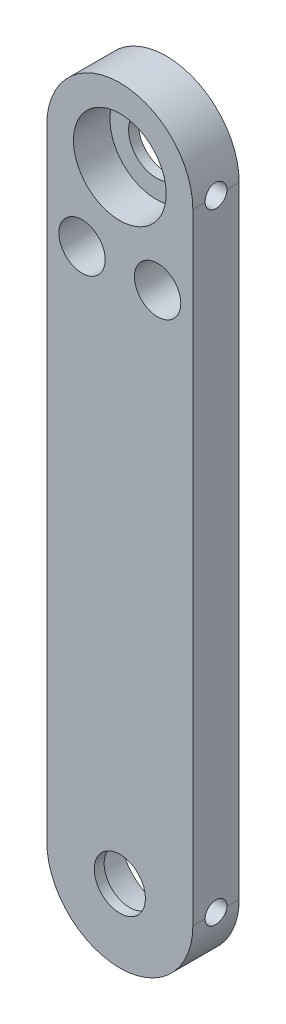
from build123d import *

# Parameters (mm, degrees)
SALIENTE_EXTRUIR1_DEPTH = 6.35
CROQUIS2_R              = 6.35
CORTAR_EXTRUIR1_DEPTH   = 5
CROQUIS3_R              = 3.8
CORTAR_EXTRUIR2_DEPTH   = 54.677276384
CROQUIS4_R              = 3.175
CORTAR_EXTRUIR3_DEPTH   = 5
CROQUIS5_R              = 1.5
CORTAR_EXTRUIR4_DEPTH   = 5
CROQUIS6_R              = 1.5
CORTAR_EXTRUIR5_DEPTH   = 5
CROQUIS7_R              = 6.35
CORTAR_EXTRUIR6_DEPTH   = 5
CROQUIS8_R              = 3.5
CORTAR_EXTRUIR7_DEPTH   = 5
CROQUIS9_R              = 1.5
CORTAR_EXTRUIR8_DEPTH   = 5


with BuildPart() as part:
    # Croquis1 → Saliente-Extruir1 (new body)
    with BuildSketch(Plane.XY):
        with BuildLine():
            Line((10, 42.5), (10, -42.5))
            ThreePointArc((10, -42.5), (0, -52.5), (-10, -42.5))
            Line((-10, -42.5), (-10, 42.5))
            ThreePointArc((-10, 42.5), (0, 52.5), (10, 42.5))
        make_face()
    extrude(amount=SALIENTE_EXTRUIR1_DEPTH)

    # Croquis2 → Cortar-Extruir1 (cut)
    with BuildSketch(Plane.XY.offset(6.35)):
        with Locations((0, 42.5)):
            Circle(CROQUIS2_R)
    extrude(amount=-CORTAR_EXTRUIR1_DEPTH, mode=Mode.SUBTRACT)

    # Croquis3 → Cortar-Extruir2 (cut, through all)
    with BuildSketch(Plane.XY.offset(1.35)):
        with Locations((0, 42.5)):
            Circle(CROQUIS3_R)
    extrude(amount=-CORTAR_EXTRUIR2_DEPTH, mode=Mode.SUBTRACT)

    # Croquis4 → Cortar-Extruir3 (cut)
    with BuildSketch(Plane.XY.offset(6.35)):
        with Locations((5.175, 30.5)):
            Circle(CROQUIS4_R)
        with Locations((-5.175, 30.5)):
            Circle(CROQUIS4_R)
    extrude(amount=-CORTAR_EXTRUIR3_DEPTH, mode=Mode.SUBTRACT)

    # Croquis5 → Cortar-Extruir4 (cut)
    with BuildSketch(Plane.XY.offset(1.35)):
        with Locations((-5.175, 30.5)):
            Circle(CROQUIS5_R)
        with Locations((5.175, 30.5)):
            Circle(CROQUIS5_R)
    extrude(amount=-CORTAR_EXTRUIR4_DEPTH, mode=Mode.SUBTRACT)

    # Croquis6 → Cortar-Extruir5 (cut)
    with BuildSketch(Plane(origin=(10, 0, 0), x_dir=(0, 0, -1), z_dir=(1, 0, 0))):
        with Locations((-3.175, 42.5)):
            Circle(CROQUIS6_R)
    extrude(amount=-CORTAR_EXTRUIR5_DEPTH, mode=Mode.SUBTRACT)

    # Croquis7 → Cortar-Extruir6 (cut)
    with BuildSketch(Plane(origin=(0, 0, 0), x_dir=(-1, 0, 0), z_dir=(0, 0, -1))):
        with Locations((0, -42.5)):
            Circle(CROQUIS7_R)
    extrude(amount=-CORTAR_EXTRUIR6_DEPTH, mode=Mode.SUBTRACT)

    # Croquis8 → Cortar-Extruir7 (cut)
    with BuildSketch(Plane(origin=(0, 0, 5), x_dir=(-1, 0, 0), z_dir=(0, 0, -1))):
        with Locations((0, -42.5)):
            Circle(CROQUIS8_R)
    extrude(amount=-CORTAR_EXTRUIR7_DEPTH, mode=Mode.SUBTRACT)

    # Croquis9 → Cortar-Extruir8 (cut)
    with BuildSketch(Plane(origin=(10, 0, 0), x_dir=(0, 0, -1), z_dir=(1, 0, 0))):
        with Locations((-3.175, -42.5)):
            Circle(CROQUIS9_R)
    extrude(amount=-CORTAR_EXTRUIR8_DEPTH, mode=Mode.SUBTRACT)


solid = part.part
